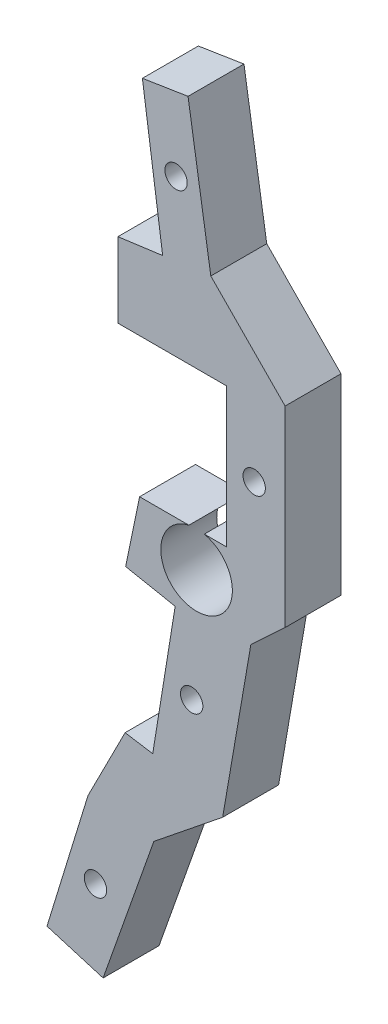
from build123d import *

# Parameters (mm, degrees)
SKETCH1_R           = 1
BOSS_EXTRUDE1_DEPTH = 5
SKETCH2_R           = 3.2
CUT_EXTRUDE1_DEPTH  = 6


with BuildPart() as part:
    # Sketch1 → Boss-Extrude1 (new body)
    with BuildSketch(Plane.XY):
        Polygon((-30.344978495, 29.354997846), (-26.26481101, 29.998979434), (-24.229853855, 17.105806435), (-17.589395727, 10.355662433), (-17.589395727, -6.795999984), (-20.648203061, -9.632059779), (-23.169168461, -24.271324462), (-29.322804804, -29.218365444), (-33.858296815, -42.061599658), (-38.875160748, -40.557320866), (-35.210826338, -28.612806279), (-31.890475236, -22.08234188), (-29.422452502, -22.48091908), (-27.416937939, -10.06260833), (-31.846007079, -9.19781647), (-30.596587071, -3.168743327), (-22.846023992, -3.168743327), (-22.846023992, 9.3), (-32.534265366, 9.3), (-32.534265366, 15.998319193), (-28.533481358, 16.537502585), align=None)
        with Locations((-27.335083026, 23.255353238)):
            Circle(SKETCH1_R, mode=Mode.SUBTRACT)
        with Locations((-20.35, 3.1)):
            Circle(SKETCH1_R, mode=Mode.SUBTRACT)
        with Locations((-25.941584057, -16.567336204)):
            Circle(SKETCH1_R, mode=Mode.SUBTRACT)
        with Locations((-34.540975654, -35.117818403)):
            Circle(SKETCH1_R, mode=Mode.SUBTRACT)
    extrude(amount=BOSS_EXTRUDE1_DEPTH)

    # Sketch2 → Cut-Extrude1 (cut, through all)
    with BuildSketch(Plane(origin=(0, 0, 0), x_dir=(-1, 0, 0), z_dir=(0, 0, -1))):
        with Locations((25.5, -6.29339012)):
            Circle(SKETCH2_R)
    extrude(amount=-CUT_EXTRUDE1_DEPTH, mode=Mode.SUBTRACT)


solid = part.part
